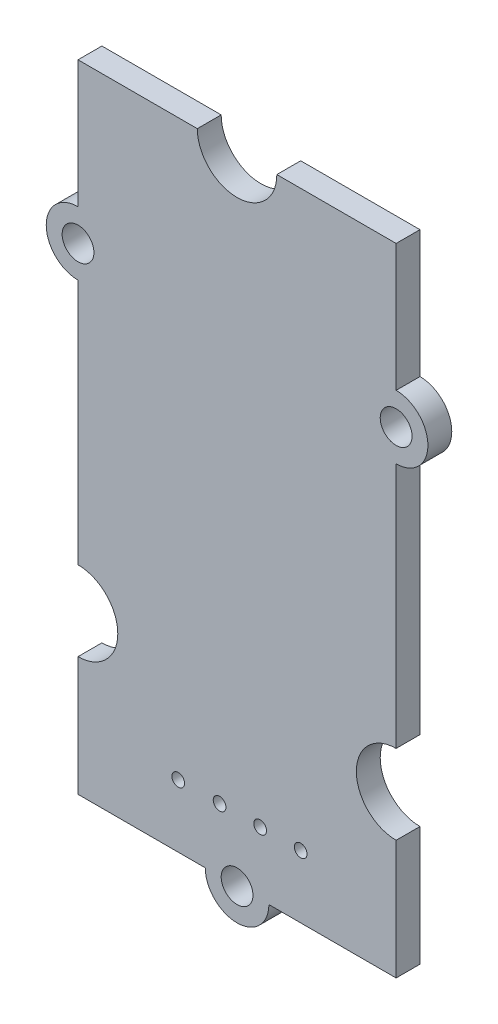
from build123d import *

# Parameters (mm, degrees)
PCB_DEPTH     = 1.5
ESQUISSE3_R   = 1
ESQUISSE3_R_2 = 0.4
TROUS_DEPTH   = 2.5


with BuildPart() as part:
    # Esquisse2 → PCB (new body)
    with BuildSketch(Plane.XY):
        with BuildLine():
            Line((-10, 0), (-2, 0))
            ThreePointArc((-2, 0), (0, -2), (2, 0))
            Line((2, 0), (10, 0))
            Line((10, 0), (10, 7.5))
            ThreePointArc((10, 7.5), (7.5, 10), (10, 12.5))
            Line((10, 12.5), (10, 28))
            ThreePointArc((10, 28), (12, 30), (10, 32))
            Line((10, 32), (10, 40))
            Line((10, 40), (2.5, 40))
            ThreePointArc((2.5, 40), (0, 37.5), (-2.5, 40))
            Line((-2.5, 40), (-10, 40))
            Line((-10, 40), (-10, 32))
            ThreePointArc((-10, 32), (-12, 30), (-10, 28))
            Line((-10, 28), (-10, 12.5))
            ThreePointArc((-10, 12.5), (-7.5, 10), (-10, 7.5))
            Line((-10, 7.5), (-10, 0))
        make_face()
    extrude(amount=PCB_DEPTH)

    # Esquisse3 → Trous (cut, through all)
    with BuildSketch(Plane.XY.offset(1.5)):
        with Locations((-10, 30)):
            Circle(ESQUISSE3_R)
        with Locations((4, 3.943417201)):
            Circle(ESQUISSE3_R_2)
        with Locations(Location((10, 30, 0), (0, 0, 180))):  # turned: the seam where the file's is
            Circle(ESQUISSE3_R)
        Circle(ESQUISSE3_R)
        with Locations((1.45, 3.943417201)):
            Circle(ESQUISSE3_R_2)
        with Locations((-1.1, 3.943417201)):
            Circle(ESQUISSE3_R_2)
        with Locations((-3.7, 3.943417201)):
            Circle(ESQUISSE3_R_2)
    extrude(amount=-TROUS_DEPTH, mode=Mode.SUBTRACT)


solid = part.part
